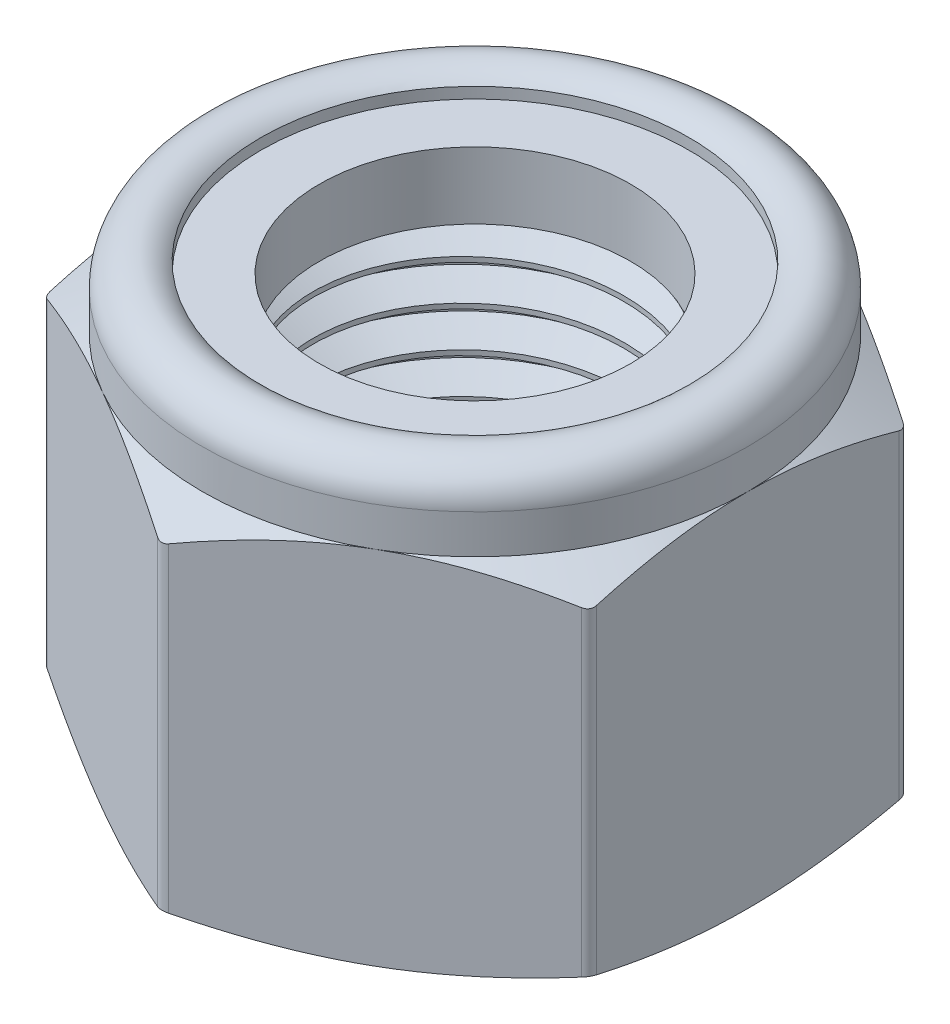
from build123d import *

# Parameters (mm, degrees)
SKETCH2_R                = 4.075092336
BOSS_EXTRUDE1_DEPTH      = 5.754688
BOSS_EXTRUDE1_DEPTH_BACK = 5.754687
FILLET1_R                = 0.28575
SKETCH4_W                = 1.534328832
SKETCH4_H                = 1.750891416
SKETCH6_W                = 4.7625
SKETCH6_H                = 9.591145833
CUT_SWEEP1_PITCH         = 1.058333333
CUT_SWEEP1_HEIGHT        = 11.509375
CUT_SWEEP1_RADIUS        = 4.7625
CUT_SWEEP1_START_ANGLE   = 90
SKETCH10_R               = 5.027592336
BOSS_EXTRUDE2_DEPTH      = 9.2075


with BuildPart() as part:
    # Sketch2 → Boss-Extrude1 (new, two sides)
    with BuildSketch(Plane(origin=(0, 0, 0), x_dir=(1, 0, 0), z_dir=(0, 1, 0))) as boss_extrude1_sk:
        Polygon((0, 8.248891971), (-7.14375, 4.124445986), (-7.14375, -4.124445986), (0, -8.248891971), (7.14375, -4.124445986), (7.14375, 4.124445986), align=None)
        with Locations(Location((0, 0, 0), (0, 0, 90))):
            Circle(SKETCH2_R, mode=Mode.SUBTRACT)
    extrude(amount=BOSS_EXTRUDE1_DEPTH)
    extrude(boss_extrude1_sk.sketch, amount=-BOSS_EXTRUDE1_DEPTH_BACK)

    # Fillet1
    fillet1_edges = [part.edges().sort_by_distance(p)[0] for p in [
        (7.14375, 5e-07, -4.124445986),
        (7.14375, 5e-07, 4.124445986),
        (0, 5e-07, 8.248891971),
        (-7.14375, 5e-07, 4.124445986),
        (-7.14375, 5e-07, -4.124445986),
        (0, 5e-07, -8.248891971),
    ]]
    fillet(fillet1_edges, radius=FILLET1_R)

    # Sketch3 → Cut-Revolve2 (revolve, cut)
    with BuildSketch(Plane(origin=(0, 0, 0), x_dir=(0, 0, -1), z_dir=(1, 0, 0)), mode=Mode.PRIVATE) as cut_revolve2_sk:
        with BuildLine():
            Line((8.248891971, 3.836458333), (8.248891971, 6.7546875))
            Line((8.248891971, 6.7546875), (4.075092336, 6.7546875))
            Line((4.075092336, 6.7546875), (4.075092336, 3.4528125))
            Line((4.075092336, 3.4528125), (5.609421168, 3.4528125))
            Line((5.609421168, 3.4528125), (5.609421168, 5.491438291))
            ThreePointArc((5.609421168, 5.491438291), (6.588912647, 5.68627126), (7.14375, 4.855898479))
            Line((7.14375, 4.855898479), (7.14375, 3.836458333))
            Line((7.14375, 3.836458333), (8.248891971, 3.187874756))
            Line((8.248891971, 3.187874756), (8.248891971, 3.836458333))
        make_face()
        Polygon((6.858, -5.7546875), (8.248891971, -5.106103922), (8.248891971, -5.7546875), align=None)
        Polygon((4.075092336, -5.7546875), (4.075092336, -4.8021875), (5.027592336, -5.7546875), align=None)
    revolve(cut_revolve2_sk.sketch.rotate(Axis((0, -5.7546875, 0), (0, 1, 0)), 270), axis=Axis((0, -5.7546875, 0), (0, 1, 0)), mode=Mode.SUBTRACT)

    # Sketch10 → Boss-Extrude2 (add)
    with BuildSketch(Plane.XZ.offset(5.7546875)):
        Circle(SKETCH10_R)
    extrude(amount=-BOSS_EXTRUDE2_DEPTH)


with BuildPart() as body_2:
    # Sketch4 → Revolve1 (revolve)
    with BuildSketch(Plane(origin=(0, 0, 0), x_dir=(0, 0, -1), z_dir=(1, 0, 0)), mode=Mode.PRIVATE) as revolve1_sk:
        with Locations((-4.842256752, 4.328258208)):
            Rectangle(SKETCH4_W, SKETCH4_H)
    revolve(revolve1_sk.sketch.rotate(Axis((0, -5.7546875, 0), (0, 1, 0)), 90), axis=Axis((0, -5.7546875, 0), (0, 1, 0)))


with BuildPart() as body_3:
    # Sketch6 → Revolve2 (revolve)
    with BuildSketch(Plane.XY, mode=Mode.PRIVATE) as revolve2_sk:
        with Locations((2.38125, -0.959114583)):
            Rectangle(SKETCH6_W, SKETCH6_H)
    revolve(revolve2_sk.sketch.rotate(Axis((0, -5.7546875, 0), (0, 1, 0)), 90), axis=Axis((0, -5.7546875, 0), (0, 1, 0)))

    # Cut-Sweep1: sweep along a helix
    with BuildLine() as cut_sweep1_path:
        add(Helix(CUT_SWEEP1_PITCH, CUT_SWEEP1_HEIGHT, CUT_SWEEP1_RADIUS, center=(0, -5.7546875, 0), direction=(0, 1, 0), mode=Mode.PRIVATE).rotate(Axis((0, -5.7546875, 0), (0, 1, 0)), CUT_SWEEP1_START_ANGLE))
    # Sketch8 → Cut-Sweep1 (sweep, cut)
    with BuildSketch(Plane.XY):
        Polygon((4.075092336, -6.1515625), (4.075092336, -6.283854167), (4.819783972, -6.713802083), (4.877067944, -5.688541667), align=None)
    sweep(path=cut_sweep1_path.line, is_frenet=True, mode=Mode.SUBTRACT)

    # Sketch9 → Revolve3 (revolve)
    with BuildSketch(Plane.XY, mode=Mode.PRIVATE) as revolve3_sk:
        Polygon((0, -0.9921875), (0, -5.7546875), (4.7625, -5.7546875), (5.715, -5.7546875), (0, -0.0396875), align=None)
    revolve(revolve3_sk.sketch.rotate(Axis((0, -0.9921875, 0), (0, -1, 0)), 151.002314411), axis=Axis((0, -0.9921875, 0), (0, -1, 0)))


with BuildPart() as part_1:
    add(part.part)

    # Combine1: cut body 3
    add(body_3.part, mode=Mode.SUBTRACT)


solid = Compound([body_2.part, part_1.part])
